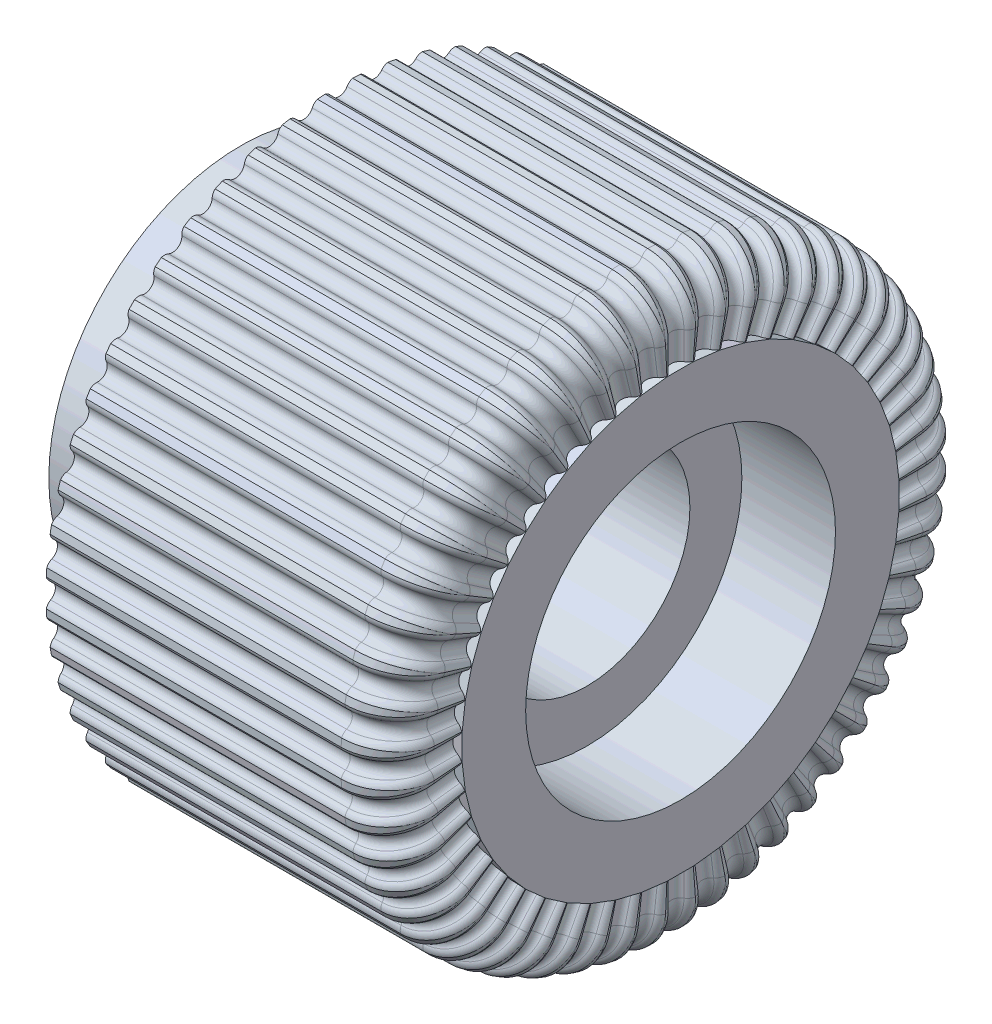
from build123d import *

# Parameters (mm, degrees)
CIRPATTERN1_COUNT = 52
CIRPATTERN1_ANGLE = 353.073


with BuildPart() as part:
    # Sketch1 → Base-Revolve (revolve)
    with BuildSketch(Plane.XY):
        with BuildLine():
            Line((0, 2.794), (0, 5.207))
            Line((0, 5.207), (4.826, 5.207))
            Line((4.826, 5.207), (4.826, 6.35))
            Line((4.826, 6.35), (2.667, 6.35))
            Line((2.667, 6.35), (2.667, 7.9502))
            Line((2.667, 7.9502), (10.668, 7.9502))
            ThreePointArc((10.668, 7.9502), (11.566025612, 7.578225612), (11.938, 6.6802))
            Line((11.938, 6.6802), (11.938, 4.204029943))
            Line((11.938, 4.204029943), (9.398, 4.204029943))
            Line((9.398, 4.204029943), (9.398, 2.794))
            Line((9.398, 2.794), (0, 2.794))
        make_face()
    revolve(axis=Axis((0, 0, 0), (1, 0, 0)))

    # Cut-Sweep1: sweep along a path in Sketch3
    with BuildLine(Plane.XY) as cut_sweep1_path:
        Line((11.684, 5.927252811), (11.684, 6.6802))
        ThreePointArc((11.684, 6.6802), (11.38642049, 7.39862049), (10.668, 7.6962))
        Line((10.668, 7.6962), (2.667, 7.6962))
    # Sketch4 → Cut-Sweep1 (sweep, cut)
    with BuildSketch(Plane(origin=(11.684, 5.927252811, 0), x_dir=(1, 0, 0), z_dir=(0, -1, 0))):
        with BuildLine():
            Line((0.254, 0.439940905), (0.254, -0.439940905))
            ThreePointArc((0.254, -0.439940905), (0.219970453, -0.312940905), (0.127, -0.219970453))
            ThreePointArc((0.127, -0.219970453), (0, 0), (0.127, 0.219970453))
            ThreePointArc((0.127, 0.219970453), (0.219970453, 0.312940905), (0.254, 0.439940905))
        make_face()
    cut_sweep1 = sweep(path=cut_sweep1_path.line, mode=Mode.SUBTRACT)

    # CirPattern1: Cut-Sweep1 ×52 about axis
    cirpattern1_axis = Axis((0, 0, 0), (1, 0, 0))
    for i in range(1, CIRPATTERN1_COUNT):
        add(cut_sweep1.rotate(cirpattern1_axis, i * CIRPATTERN1_ANGLE / (CIRPATTERN1_COUNT - 1)), mode=Mode.SUBTRACT)


solid = part.part
